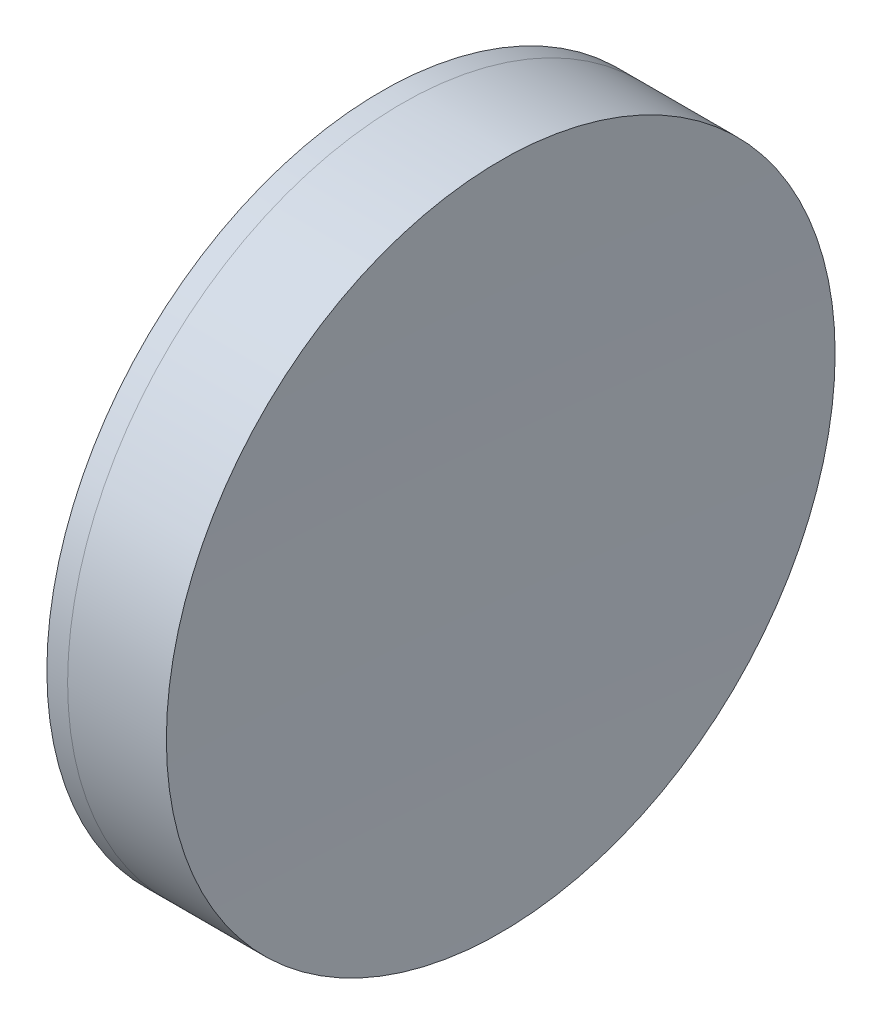
from build123d import *


with BuildPart() as part:
    # 草图1 one side → 旋转1 (revolve)
    with BuildSketch(Plane(origin=(0, 0, 0), x_dir=(1, 0, 0), z_dir=(0, 1, 0)), mode=Mode.PRIVATE) as revolve_1_sk:
        with BuildLine():
            ThreePointArc((302.508639841, 12.7), (300.822236845, 6.449266686), (300.254274486, 0))
            Line((300.254274486, 0), (305.254274486, 0))
            ThreePointArc((305.254274486, 0), (304.761943914, 6.425011371), (303.296448016, 12.7))
            Line((303.296448016, 12.7), (302.508639841, 12.7))
        make_face()
    revolve(revolve_1_sk.sketch.rotate(Axis((124.523309526, 0, 0), (1, 0, 0)), 180), axis=Axis((124.523309526, 0, 0), (1, 0, 0)))  # turned: the seam where the file's is


with BuildPart() as body_2:
    # 草图2 one side → 旋转3 (revolve)
    with BuildSketch(Plane(origin=(0, 0, 0), x_dir=(1, 0, 0), z_dir=(0, 1, 0)), mode=Mode.PRIVATE) as revolve_3_sk:
        with BuildLine():
            Line((307.047342073, 12.7), (303.296448016, 12.7))
            ThreePointArc((303.296448016, 12.7), (304.761943914, 6.425011371), (305.254274486, 0))
            Line((305.254274486, 0), (306.854274486, 0))
            ThreePointArc((306.854274486, 0), (306.902544171, 6.350733719), (307.047342073, 12.7))
        make_face()
    revolve(revolve_3_sk.sketch.rotate(Axis((-0.551919993, 0, 0), (1, 0, 0)), 180), axis=Axis((-0.551919993, 0, 0), (1, 0, 0)))  # turned: the seam where the file's is


solid = Compound([part.part, body_2.part])
